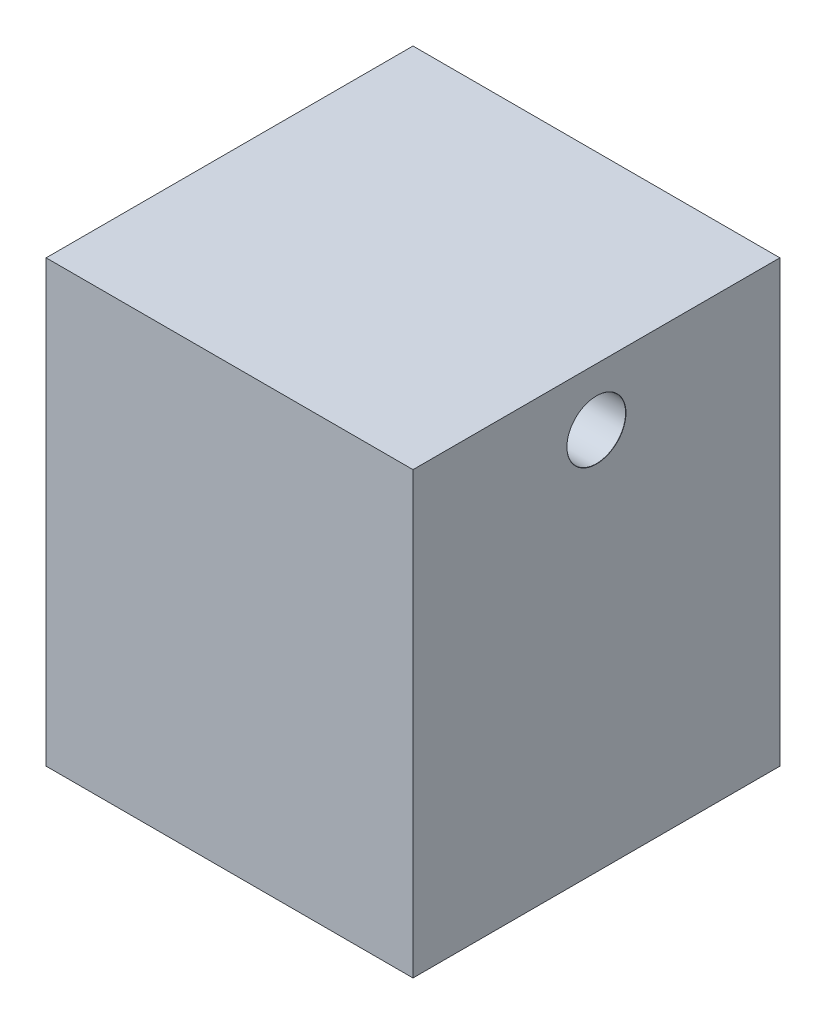
from build123d import *

# Parameters (mm, degrees)
SKETCH1_W                       = 50
SKETCH1_H                       = 50
BOSS_EXTRUDE1_DEPTH             = 60
F_8_0MM_DOWEL_HOLE1_D           = 8
F_8_0MM_DOWEL_HOLE1_CSINK_D     = 8.05
F_8_0MM_DOWEL_HOLE1_CSINK_ANGLE = 90


with BuildPart() as part:
    # Sketch1 → Boss-Extrude1 (new body)
    with BuildSketch(Plane(origin=(0, 0, 0), x_dir=(1, 0, 0), z_dir=(0, 1, 0))):
        Rectangle(SKETCH1_W, SKETCH1_H)
    extrude(amount=BOSS_EXTRUDE1_DEPTH)

    # Ø8.0mm Dowel Hole1 (through all)
    with Locations(Plane(origin=(25, 0, 0), x_dir=(0, 0, -1), z_dir=(1, 0, 0))):
        with Locations((0, 52.184072135)):
            CounterSinkHole(F_8_0MM_DOWEL_HOLE1_D / 2, F_8_0MM_DOWEL_HOLE1_CSINK_D / 2, counter_sink_angle=F_8_0MM_DOWEL_HOLE1_CSINK_ANGLE)


solid = part.part
